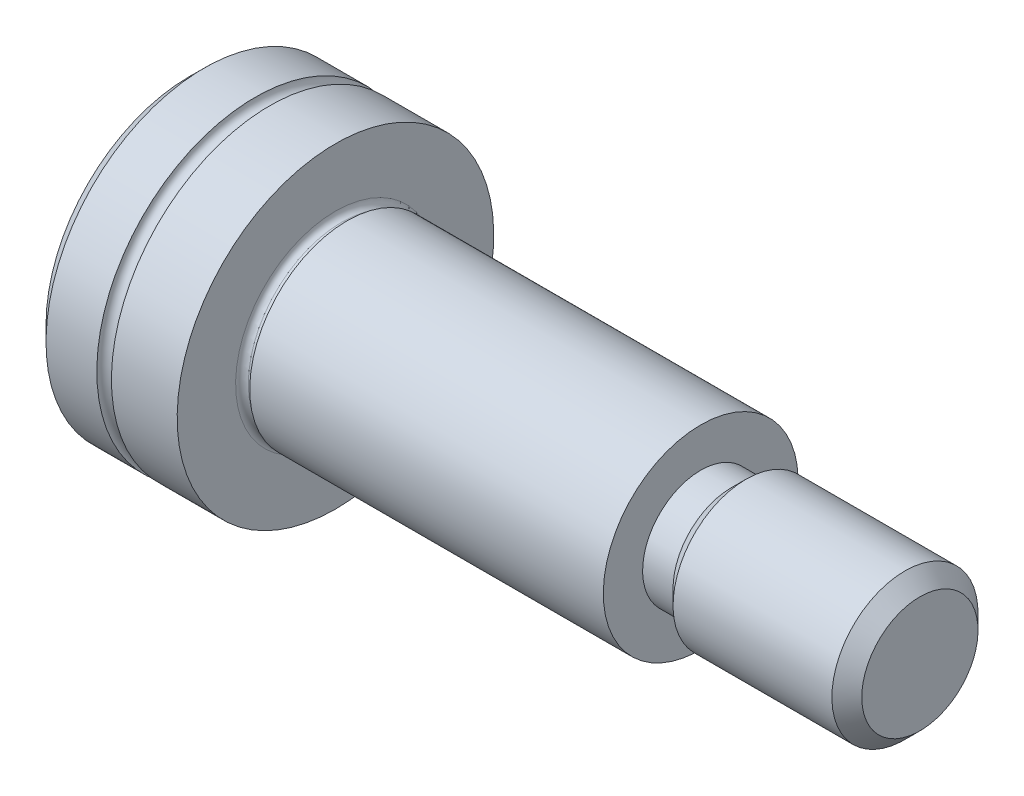
from build123d import *

# Parameters (mm, degrees)
SKETCH2_R           = 3.84
BOSS_EXTRUDE1_DEPTH = 0.387623957
SKETCH3_R           = 3.84
BOSS_EXTRUDE2_DEPTH = 0.092376043
BOSS_EXTRUDE2_TAPER = -60.000000004
SKETCH4_R           = 4
BOSS_EXTRUDE3_DEPTH = 14.52
SKETCH5_R           = 2.3865
BOSS_EXTRUDE4_DEPTH = 1.25
SKETCH6_R           = 2.3865
BOSS_EXTRUDE5_DEPTH = 0.6135
BOSS_EXTRUDE5_TAPER = -45
SKETCH7_R           = 3
BOSS_EXTRUDE6_DEPTH = 7.1365
CUT_EXTRUDE1_DEPTH  = 3
CHAMFER1_SIZE       = 0.6135
FILLET1_R           = 0.261


with BuildPart() as part:
    # Sketch1 → Revolve1 (revolve)
    with BuildSketch(Plane(origin=(0, 0, 0), x_dir=(-1, 0, 0), z_dir=(0, 0, -1))):
        with BuildLine():
            Line((0, 6.5), (0, 0))
            Line((0, 0), (6, 0))
            Line((6, 0), (6, 6.5))
            Line((6, 6.5), (3.3, 6.5))
            ThreePointArc((3.3, 6.5), (3, 6.2), (2.7, 6.5))
            Line((2.7, 6.5), (0, 6.5))
        make_face()
    revolve(axis=Axis((0, 0, 0), (-1, 0, 0)))

    # Sketch2 → Boss-Extrude1 (add)
    with BuildSketch(Plane(origin=(0, 0, 0), x_dir=(0, 0, -1), z_dir=(1, 0, 0))):
        Circle(SKETCH2_R)
    extrude(amount=BOSS_EXTRUDE1_DEPTH)

    # Sketch3 → Boss-Extrude2 (add)
    with BuildSketch(Plane(origin=(0.387623957, 0, 0), x_dir=(0, 0, -1), z_dir=(1, 0, 0))):
        Circle(SKETCH3_R)
    extrude(amount=BOSS_EXTRUDE2_DEPTH, taper=BOSS_EXTRUDE2_TAPER)

    # Sketch4 → Boss-Extrude3 (add)
    with BuildSketch(Plane(origin=(0.48, 0, 0), x_dir=(0, 0, -1), z_dir=(1, 0, 0))):
        Circle(SKETCH4_R)
    extrude(amount=BOSS_EXTRUDE3_DEPTH)

    # Sketch5 → Boss-Extrude4 (add)
    with BuildSketch(Plane(origin=(15, 0, 0), x_dir=(0, 0, -1), z_dir=(1, 0, 0))):
        Circle(SKETCH5_R)
    extrude(amount=BOSS_EXTRUDE4_DEPTH)

    # Sketch6 → Boss-Extrude5 (add)
    with BuildSketch(Plane(origin=(16.25, 0, 0), x_dir=(0, 0, -1), z_dir=(1, 0, 0))):
        Circle(SKETCH6_R)
    extrude(amount=BOSS_EXTRUDE5_DEPTH, taper=BOSS_EXTRUDE5_TAPER)

    # Sketch7 → Boss-Extrude6 (add)
    with BuildSketch(Plane(origin=(16.8635, 0, 0), x_dir=(0, 0, -1), z_dir=(1, 0, 0))):
        Circle(SKETCH7_R)
    extrude(amount=BOSS_EXTRUDE6_DEPTH)

    # Sketch8 → Cut-Extrude1 (cut)
    with BuildSketch(Plane.ZY.offset(6)):
        Polygon((2.5, -1.443375673), (2.5, 1.443375673), (0, 2.886751346), (-2.5, 1.443375673), (-2.5, -1.443375673), (0, -2.886751346), align=None)
    extrude(amount=-CUT_EXTRUDE1_DEPTH, mode=Mode.SUBTRACT)

    # Sketch9 → Cut-Revolve1 (revolve, cut)
    with BuildSketch(Plane.XY):
        Polygon((-3, 2.4), (-3, 0), (-1.614359354, 0), align=None)
    revolve(axis=Axis((-3, 0, 0), (1, 0, 0)), mode=Mode.SUBTRACT)

    # Chamfer1
    chamfer1_edges = [part.edges().sort_by_distance(p)[0] for p in [
        (24, 0, 3),
        (-6, -6.5, 0),
    ]]
    chamfer(chamfer1_edges, length=CHAMFER1_SIZE)

    # Fillet1
    fillet1_edges = [part.edges().sort_by_distance(p)[0] for p in [
        (0, 0, 3.84),
    ]]
    fillet(fillet1_edges, radius=FILLET1_R)


solid = part.part
